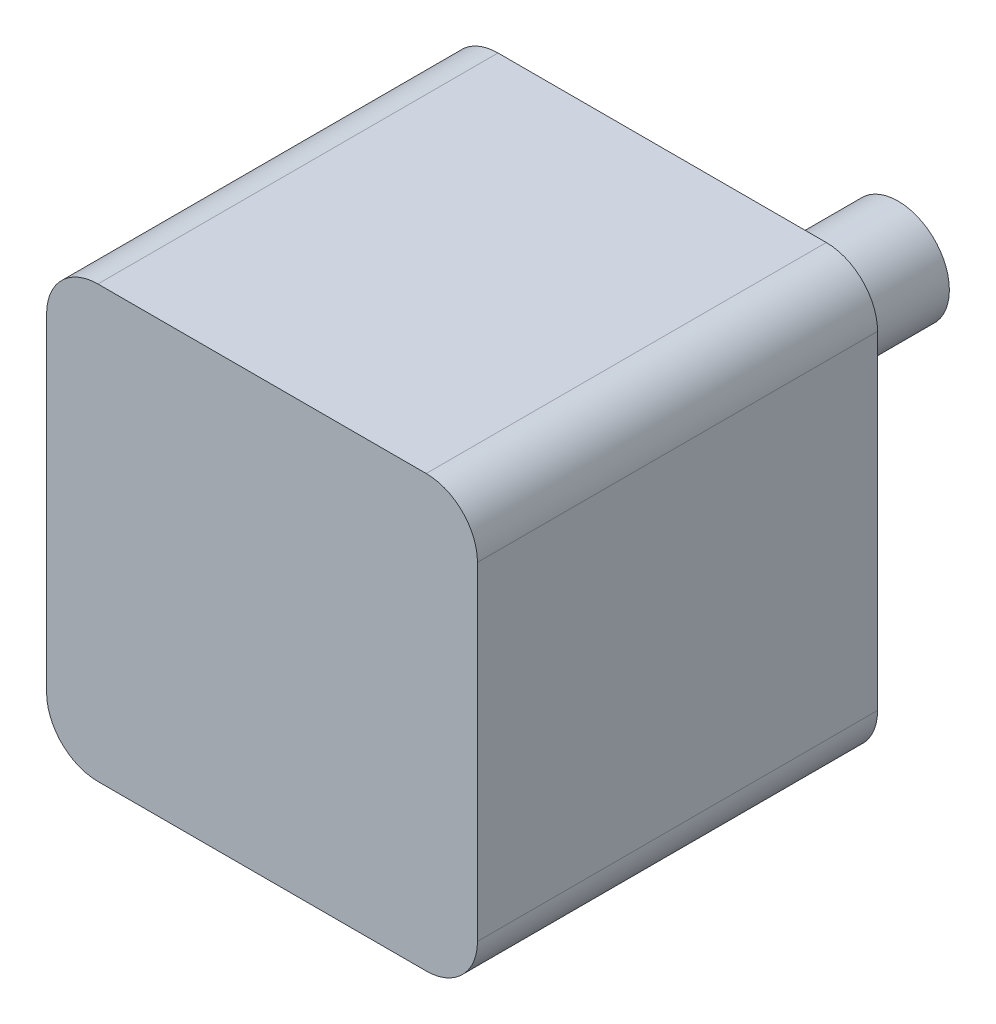
from build123d import *

# Parameters (mm, degrees)
ESQUISSE1_W        = 42
ESQUISSE1_H        = 42
BOSS_EXTRU_1_DEPTH = 39
CONG_1_R           = 5
ESQUISSE2_R        = 5
BOSS_EXTRU_2_DEPTH = 23


with BuildPart() as part:
    # Esquisse1 → Boss.-Extru.1 (new body)
    with BuildSketch(Plane.XY):
        with Locations((21, -21)):
            Rectangle(ESQUISSE1_W, ESQUISSE1_H)
    extrude(amount=BOSS_EXTRU_1_DEPTH)

    # Congé1
    cong_1_edges = [part.edges().sort_by_distance(p)[0] for p in [
        (0, 0, 19.5),
        (42, 0, 19.5),
        (42, -42, 19.5),
        (0, -42, 19.5),
    ]]
    fillet(cong_1_edges, radius=CONG_1_R)

    # Esquisse2 → Boss.-Extru.2 (add)
    with BuildSketch(Plane(origin=(0, 0, 0), x_dir=(-1, 0, 0), z_dir=(0, 0, -1))):
        with Locations((-21, -21)):
            Circle(ESQUISSE2_R)
    extrude(amount=BOSS_EXTRU_2_DEPTH)


solid = part.part
